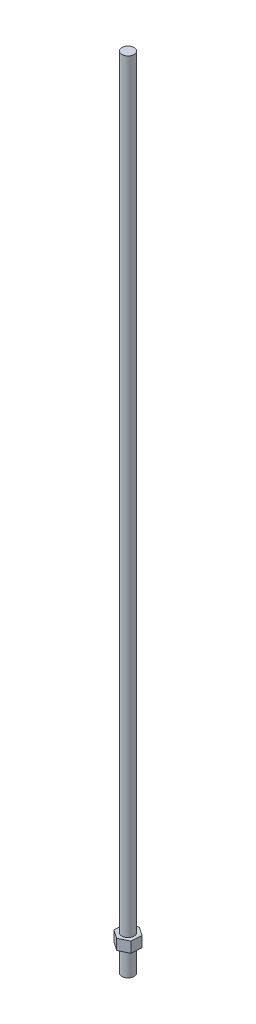
from build123d import *

# Parameters (mm, degrees)
SKETCH1_R           = 6.35
BOSS_EXTRUDE1_DEPTH = 831.85
BOSS_EXTRUDE2_START = 25.4
BOSS_EXTRUDE2_DEPTH = 11.049


with BuildPart() as part:
    # Sketch1 → Boss-Extrude1 (new body)
    with BuildSketch(Plane(origin=(0, 0, 0), x_dir=(1, 0, 0), z_dir=(0, 1, 0))):
        Circle(SKETCH1_R)
    extrude(amount=BOSS_EXTRUDE1_DEPTH)

    # Sketch3 → Boss-Extrude2 (add)
    with BuildSketch(Plane(origin=(0, 0, 0), x_dir=(1, 0, 0), z_dir=(0, 1, 0)).offset(BOSS_EXTRUDE2_START)):
        Polygon((9.876865428, 4.838907863), (0.747815578, 10.973070302), (-9.129049851, 6.134162439), (-9.876865428, -4.838907863), (-0.747815578, -10.973070302), (9.129049851, -6.134162439), align=None)
    extrude(amount=BOSS_EXTRUDE2_DEPTH)


solid = part.part
